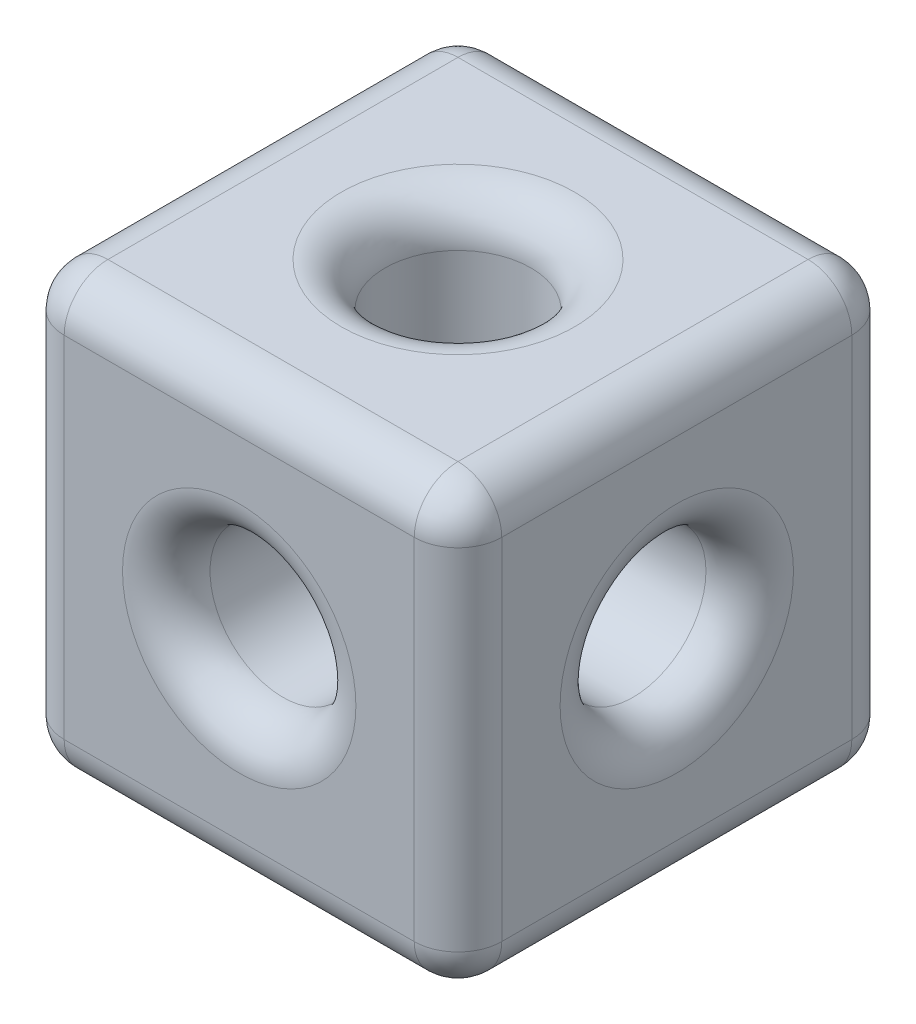
from build123d import *

# Parameters (mm, degrees)
SKETCH_1_W           = 6
SKETCH_1_H           = 6
EXTRUDE_1_DEPTH      = 3
EXTRUDE_1_DEPTH_BACK = 3
SKETCH_2_R           = 1
CUT_EXTRUDE_1_DEPTH  = 7
SKETCH_3_R           = 1
CUT_EXTRUDE_2_DEPTH  = 7
SKETCH_4_R           = 1
CUT_EXTRUDE_3_DEPTH  = 7
FILLET_1_R           = 0.6


with BuildPart() as part:
    # Sketch 1 → Extrude 1 (new body, two sides)
    with BuildSketch(Plane(origin=(0, 0, 0), x_dir=(1, 0, 0), z_dir=(0, 1, 0))) as extrude_1_sk:
        Rectangle(SKETCH_1_W, SKETCH_1_H)
    extrude(amount=EXTRUDE_1_DEPTH)
    extrude(extrude_1_sk.sketch, amount=-EXTRUDE_1_DEPTH_BACK)

    # Sketch 2 → Cut-Extrude 1 (cut, through all)
    with BuildSketch(Plane.XY.offset(3)):
        Circle(SKETCH_2_R)
    extrude(amount=-CUT_EXTRUDE_1_DEPTH, mode=Mode.SUBTRACT)

    # Sketch 3 → Cut-Extrude 2 (cut, through all)
    with BuildSketch(Plane(origin=(3, 0, 0), x_dir=(0, 0, -1), z_dir=(1, 0, 0))):
        Circle(SKETCH_3_R)
    extrude(amount=-CUT_EXTRUDE_2_DEPTH, mode=Mode.SUBTRACT)

    # Sketch 4 → Cut-Extrude 3 (cut, through all)
    with BuildSketch(Plane(origin=(0, 3, 0), x_dir=(1, 0, 0), z_dir=(0, 1, 0))):
        Circle(SKETCH_4_R)
    extrude(amount=-CUT_EXTRUDE_3_DEPTH, mode=Mode.SUBTRACT)

    # Fillet 1
    fillet_1_edges = [part.edges().sort_by_distance(p)[0] for p in [
        (3, 3, 0),
        (-3, -3, 0),
        (0, 3, -3),
        (-3, 3, 0),
        (0, 3, 3),
        (0, -3, 3),
        (-1, 0, -3),
        (-1, 0, 3),
        (-3, 0, 1),
        (3, 0, 1),
        (3, -3, 0),
        (-1, -3, 0),
        (-1, 3, 0),
        (3, 0, 3),
        (-3, 0, 3),
        (-3, 0, -3),
        (3, 0, -3),
        (0, -3, -3),
    ]]
    fillet(fillet_1_edges, radius=FILLET_1_R)


solid = part.part
